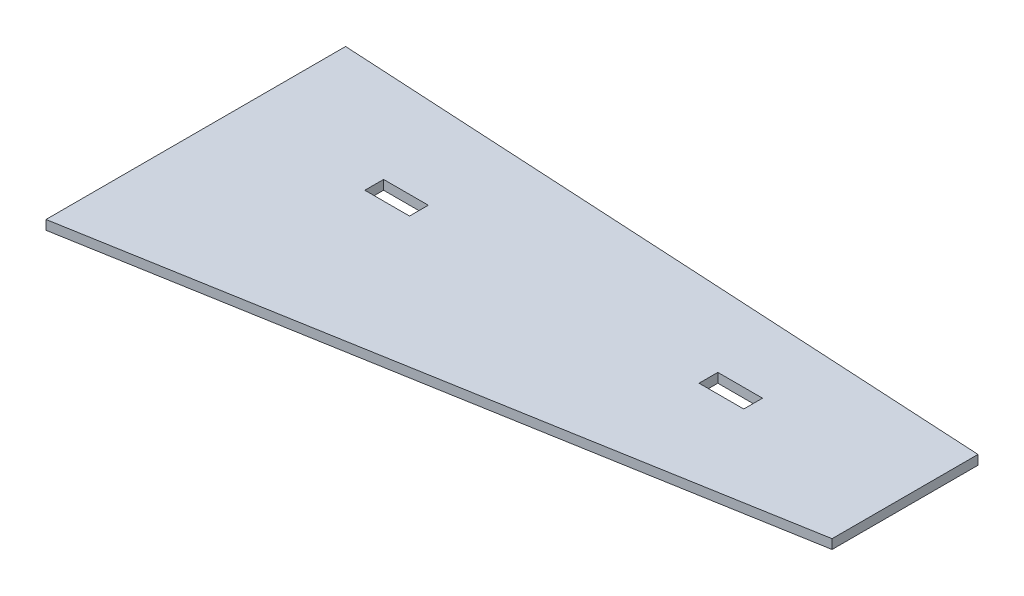
from build123d import *

# Parameters (mm, degrees)
BASE_DEPTH         = 5.334
CUT_EXTRUDE1_REACH = 7.334
SKETCH3_W          = 25.4
SKETCH3_H          = 10.668


with BuildPart() as part:
    # Sketch1 → Base (new body)
    with BuildSketch(Plane(origin=(0, 0, 0), x_dir=(1, 0, 0), z_dir=(0, 1, 0))):
        Polygon((0, 0), (380.417035208, -21.068443786), (380.417035208, -103.983742074), (0, -170.235385513), align=None)
    extrude(amount=BASE_DEPTH)

    # Sketch3 → Cut-Extrude1 (cut, up to next)
    with BuildSketch(Plane.XZ, mode=Mode.PRIVATE) as cut_extrude1_sk1:
        with Locations((278.817035208, 59.945526857)):
            Rectangle(SKETCH3_W, SKETCH3_H)
    cut_extrude1_tool1 = extrude(cut_extrude1_sk1.sketch, amount=-CUT_EXTRUDE1_REACH, mode=Mode.PRIVATE) & part.part
    add(cut_extrude1_tool1.solids().sort_by_distance((278.817035, 0, 59.945527))[0], mode=Mode.SUBTRACT)
    # Sketch3 → Cut-Extrude1 (cut, up to next)
    with BuildSketch(Plane.XZ, mode=Mode.PRIVATE) as cut_extrude1_sk2:
        with Locations((88.9, 59.945526857)):
            Rectangle(SKETCH3_W, SKETCH3_H)
    cut_extrude1_tool2 = extrude(cut_extrude1_sk2.sketch, amount=-CUT_EXTRUDE1_REACH, mode=Mode.PRIVATE) & part.part
    add(cut_extrude1_tool2.solids().sort_by_distance((88.9, 0, 59.945527))[0], mode=Mode.SUBTRACT)


solid = part.part
